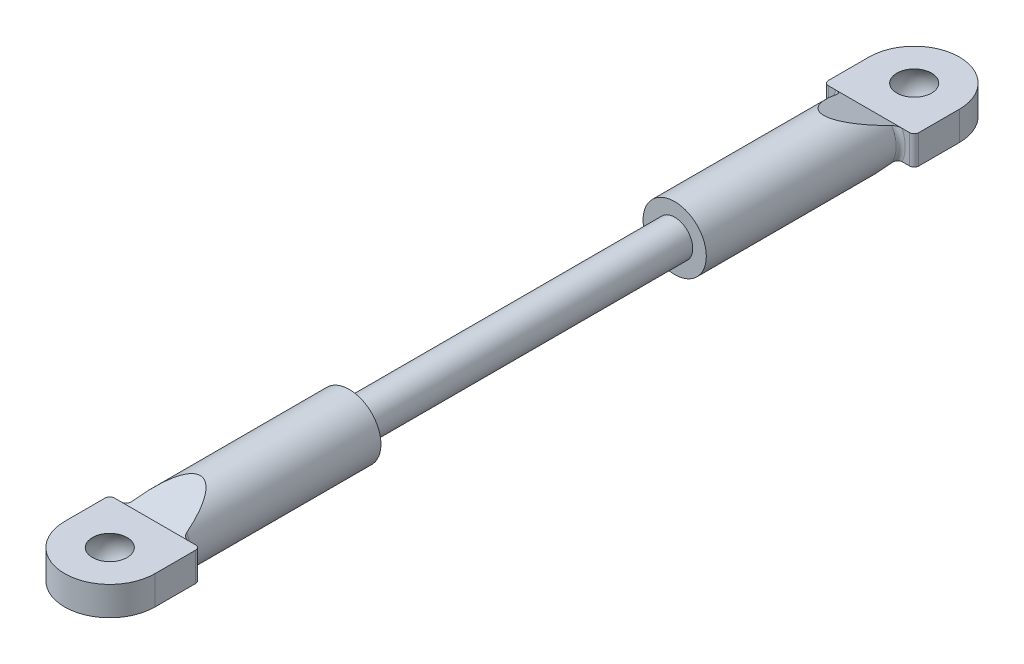
from build123d import *

# Parameters (mm, degrees)
SKETCH1_R                  = 2
SCREW_SECTION_DEPTH        = 18
SKETCH2_R                  = 3.5
BAR_SECTION_DEPTH          = 21.5
MOUNT_SECTION_DEPTH        = 1.6
BAR_TAPER_DEPTH            = 6
MOUNT_FILLET_R             = 0.5
MOUNT_FILLET_OF_MIRROR_2_R = 0.5


with BuildPart() as part:
    # Sketch1 → Screw Section (new body)
    with BuildSketch(Plane.XY):
        Circle(SKETCH1_R)
    screw_section = extrude(amount=SCREW_SECTION_DEPTH)

    # Sketch2 → Bar Section (add)
    with BuildSketch(Plane.XY.offset(18)):
        Circle(SKETCH2_R)
    bar_section = extrude(amount=BAR_SECTION_DEPTH)

    # Sketch3 → Mount Section (add, symmetric)
    with BuildSketch(Plane(origin=(0, 0, 0), x_dir=(1, 0, 0), z_dir=(0, 1, 0))):
        with BuildLine():
            Line((5, -39.5), (-5, -39.5))
            Line((-5, -39.5), (-5, -44.5))
            ThreePointArc((-5, -44.5), (0, -49.5), (5, -44.5))
            Line((5, -44.5), (5, -39.5))
        make_face()
    mount_section = extrude(amount=MOUNT_SECTION_DEPTH, both=True)

    # Sketch4 → Bar Taper (cut, symmetric)
    with BuildSketch(Plane(origin=(0, 0, 0), x_dir=(0, 0, -1), z_dir=(1, 0, 0))):
        Polygon((-34.5, -3.5), (-39.5, -1.6), (-39.5, -3.5), align=None)
        Polygon((-34.5, 3.5), (-39.5, 1.6), (-39.5, 3.5), align=None)
    bar_taper = extrude(amount=BAR_TAPER_DEPTH, both=True, mode=Mode.SUBTRACT)

    # Mount Fillet
    mount_fillet_edges = [part.edges().sort_by_distance(p)[0] for p in [
        (-5, 0, 39.5),
        (3.401842713, -0.823083322, 39.5),
        (-3.5, 0, 39.5),
        (5, 0, 39.5),
    ]]
    fillet(mount_fillet_edges, radius=MOUNT_FILLET_R)

    # Sketch6 → Ball Hole (revolve, cut)
    with BuildSketch(Plane(origin=(0, 0, 0), x_dir=(0, 0, -1), z_dir=(1, 0, 0))):
        with BuildLine():
            Line((-46.420937271, -1.6), (-44.5, -1.6))
            Line((-44.5, -1.6), (-44.5, 1.6))
            Line((-44.5, 1.6), (-46.420937271, 1.6))
            ThreePointArc((-46.420937271, 1.6), (-47, 0), (-46.420937271, -1.6))
        make_face()
    ball_hole = revolve(axis=Axis((0, -1.6, 44.5), (0, 1, 0)), mode=Mode.SUBTRACT)

    # Mirror 2: Screw Section, Bar Section, Mount Section, Bar Taper, Ball Hole across Front Plane
    add(screw_section.mirror(Plane.XY))
    add(bar_section.mirror(Plane.XY))
    add(mount_section.mirror(Plane.XY))
    add(bar_taper.mirror(Plane.XY), mode=Mode.SUBTRACT)
    add(ball_hole.mirror(Plane.XY), mode=Mode.SUBTRACT)

    # Mount Fillet of Mirror 2
    mount_fillet_of_mirror_2_edges = [part.edges().sort_by_distance(p)[0] for p in [
        (-5, 0, -39.5),
        (3.401842713, -0.823083322, -39.5),
        (-3.5, 0, -39.5),
        (5, 0, -39.5),
    ]]
    fillet(mount_fillet_of_mirror_2_edges, radius=MOUNT_FILLET_OF_MIRROR_2_R)


solid = part.part
